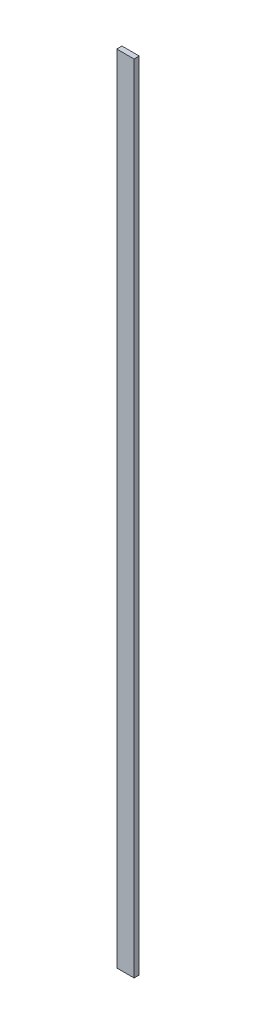
from build123d import *

# Parameters (mm, degrees)
ESQUISSE1_W        = 10
ESQUISSE1_H        = 460
BOSS_EXTRU_1_DEPTH = 3


with BuildPart() as part:
    # Esquisse1 → Boss.-Extru.1 (new body)
    with BuildSketch(Plane.XY):
        with Locations((-28.908474102, -217.055023387)):
            Rectangle(ESQUISSE1_W, ESQUISSE1_H)
    extrude(amount=BOSS_EXTRU_1_DEPTH)


solid = part.part
